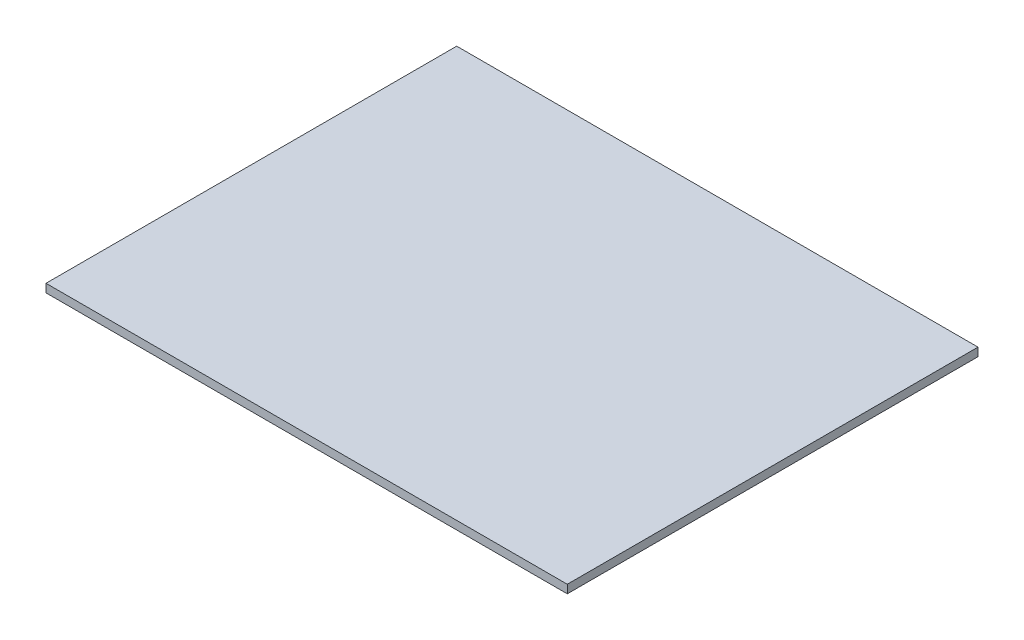
from build123d import *

# Parameters (mm, degrees)
SKETCH1_W           = 99
SKETCH1_H           = 78
BOSS_EXTRUDE1_DEPTH = 0.79


with BuildPart() as part:
    # Sketch1 → Boss-Extrude1 (new body, symmetric)
    with BuildSketch(Plane(origin=(0, 0, 0), x_dir=(1, 0, 0), z_dir=(0, 1, 0))):
        Rectangle(SKETCH1_W, SKETCH1_H)
    extrude(amount=BOSS_EXTRUDE1_DEPTH, both=True)


solid = part.part
